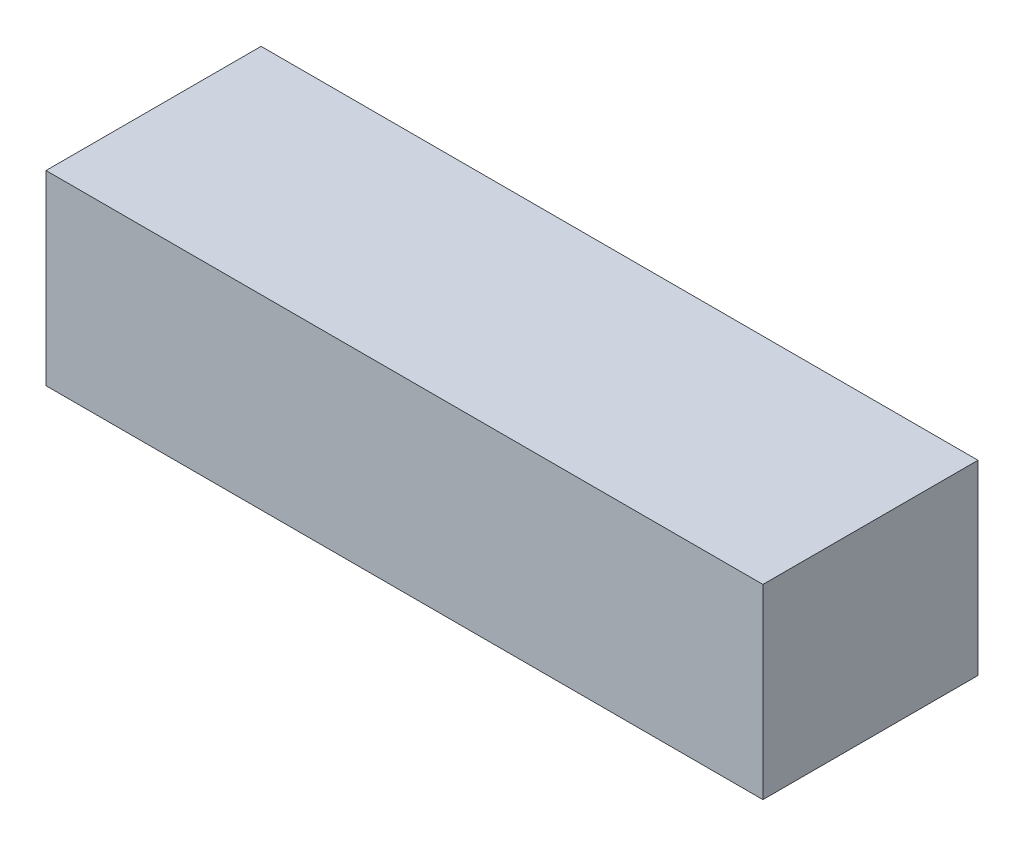
from build123d import *

# Parameters (mm, degrees)
SKETCH1_W           = 500
SKETCH1_H           = 150
BOSS_EXTRUDE1_DEPTH = 130


with BuildPart() as part:
    # Sketch1 → Boss-Extrude1 (new body)
    with BuildSketch(Plane(origin=(0, 0, 0), x_dir=(1, 0, 0), z_dir=(0, 1, 0))):
        Rectangle(SKETCH1_W, SKETCH1_H)
    extrude(amount=BOSS_EXTRUDE1_DEPTH)


solid = part.part
